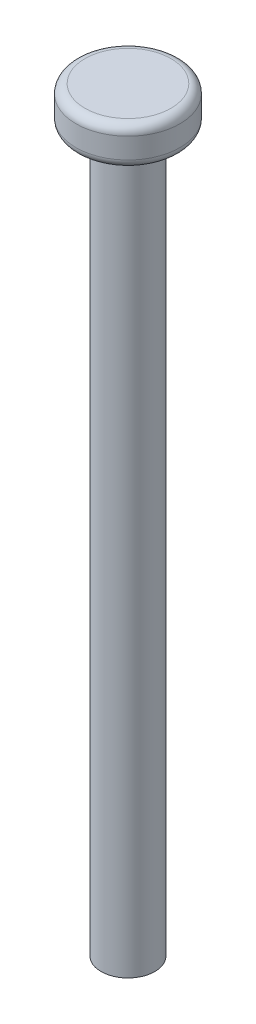
from build123d import *

# Parameters (mm, degrees)
SKETCH1_R           = 3
BOSS_EXTRUDE1_DEPTH = 80
SKETCH2_R           = 5.8
BOSS_EXTRUDE2_DEPTH = 4.3
FILLET1_R           = 1


with BuildPart() as part:
    # Sketch1 → Boss-Extrude1 (new body)
    with BuildSketch(Plane(origin=(0, 0, 0), x_dir=(1, 0, 0), z_dir=(0, 1, 0))):
        with Locations(Location((0, 0, 0), (0, 0, 270))):  # turned: the seam where the file's is
            Circle(SKETCH1_R)
    extrude(amount=BOSS_EXTRUDE1_DEPTH)

    # Sketch2 → Boss-Extrude2 (add)
    with BuildSketch(Plane(origin=(0, 80, 0), x_dir=(1, 0, 0), z_dir=(0, 1, 0))):
        with Locations(Location((0, 0, 0), (0, 0, 270))):  # turned: the seam where the file's is
            Circle(SKETCH2_R)
    extrude(amount=BOSS_EXTRUDE2_DEPTH)

    # Fillet1
    fillet1_edges = [part.edges().sort_by_distance(p)[0] for p in [
        (0, 80, -5.8),
        (0, 84.3, -5.8),
    ]]
    fillet(fillet1_edges, radius=FILLET1_R)


solid = part.part
